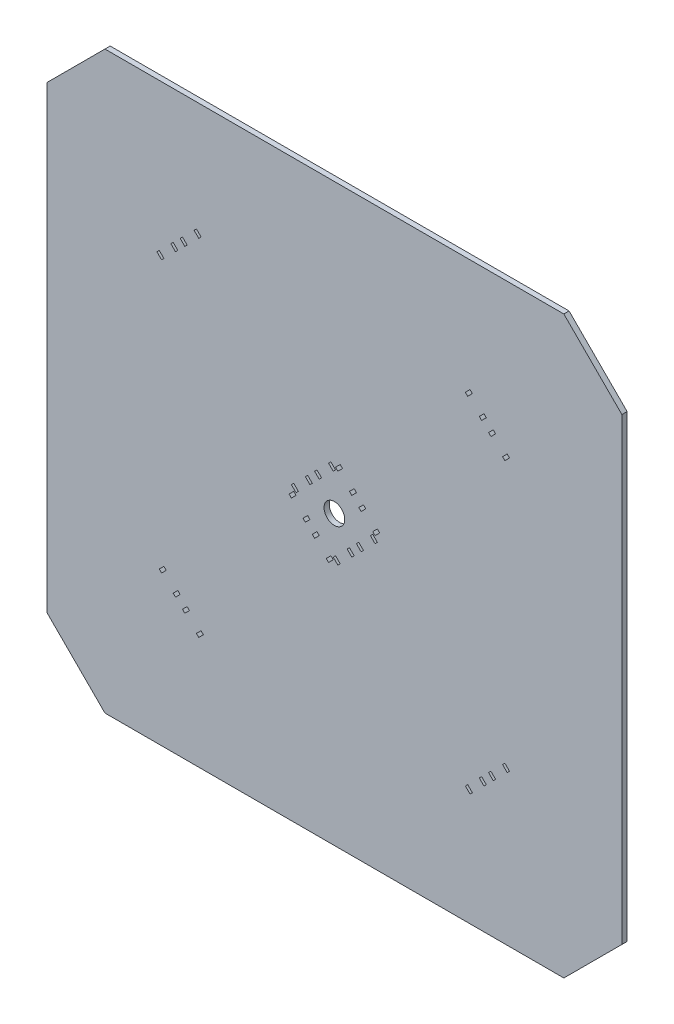
from build123d import *

# Parameters (mm, degrees)
MODEL_R             = 3.15
BOSS_EXTRUDE1_DEPTH = 1.59


with BuildPart() as part:
    # Model → Boss-Extrude1 (new body)
    with BuildSketch(Plane.XY):
        Polygon((0, 17.67766953), (0, 157.32233047), (17.67766953, 175), (157.32233047, 175), (175, 157.32233047), (175, 17.67766953), (157.32233047, 0), (17.67766953, 0), align=None)
        with Locations((87.5, 87.5)):
            Circle(MODEL_R, mode=Mode.SUBTRACT)
        Polygon((139.381727984, 47.639087297), (140.795941546, 46.224873734), (140.088834765, 45.517766953), (138.674621202, 46.931980515), align=None, mode=Mode.SUBTRACT)
        Polygon((135.139087297, 43.396446609), (136.553300859, 41.982233047), (135.846194078, 41.275126266), (134.431980515, 42.689339828), align=None, mode=Mode.SUBTRACT)
        Polygon((132.310660172, 40.568019485), (133.724873734, 39.153805922), (133.017766953, 38.446699141), (131.603553391, 39.860912703), align=None, mode=Mode.SUBTRACT)
        Polygon((128.068019485, 36.325378798), (129.482233047, 34.911165235), (128.775126266, 34.204058454), (127.360912703, 35.618272016), align=None, mode=Mode.SUBTRACT)
        Polygon((87.853553391, 76.539844892), (89.267766953, 75.125631329), (88.560660172, 74.418524548), (87.146446609, 75.83273811), align=None, mode=Mode.SUBTRACT)
        Polygon((92.096194078, 80.782485579), (93.51040764, 79.368272016), (92.803300859, 78.661165235), (91.389087297, 80.075378798), align=None, mode=Mode.SUBTRACT)
        Polygon((47.639087297, 35.618272016), (46.224873734, 34.204058454), (45.517766953, 34.911165235), (46.931980515, 36.325378798), align=None, mode=Mode.SUBTRACT)
        Polygon((43.396446609, 39.860912703), (41.982233047, 38.446699141), (41.275126266, 39.153805922), (42.689339828, 40.568019485), align=None, mode=Mode.SUBTRACT)
        Polygon((40.568019485, 42.689339828), (39.153805922, 41.275126266), (38.446699141, 41.982233047), (39.860912703, 43.396446609), align=None, mode=Mode.SUBTRACT)
        Polygon((36.325378798, 46.931980515), (34.911165235, 45.517766953), (34.204058454, 46.224873734), (35.618272016, 47.639087297), align=None, mode=Mode.SUBTRACT)
        Polygon((75.83273811, 86.439339828), (74.418524548, 85.025126266), (73.711417767, 85.732233047), (75.125631329, 87.146446609), align=None, mode=Mode.SUBTRACT)
        Polygon((80.075378798, 82.196699141), (78.661165235, 80.782485579), (77.954058454, 81.48959236), (79.368272016, 82.903805922), align=None, mode=Mode.SUBTRACT)
        Polygon((82.903805922, 79.368272016), (81.48959236, 77.954058454), (80.782485579, 78.661165235), (82.196699141, 80.075378798), align=None, mode=Mode.SUBTRACT)
        Polygon((87.146446609, 75.125631329), (85.732233047, 73.711417767), (85.025126266, 74.418524548), (86.439339828, 75.83273811), align=None, mode=Mode.SUBTRACT)
        Polygon((101.288582233, 89.267766953), (99.874368671, 87.853553391), (99.16726189, 88.560660172), (100.581475452, 89.974873734), align=None, mode=Mode.SUBTRACT)
        Polygon((97.045941546, 93.51040764), (95.631727984, 92.096194078), (94.924621202, 92.803300859), (96.338834765, 94.217514421), align=None, mode=Mode.SUBTRACT)
        Polygon((94.217514421, 96.338834765), (92.803300859, 94.924621202), (92.096194078, 95.631727984), (93.51040764, 97.045941546), align=None, mode=Mode.SUBTRACT)
        Polygon((89.974873734, 100.581475452), (88.560660172, 99.16726189), (87.853553391, 99.874368671), (89.267766953, 101.288582233), align=None, mode=Mode.SUBTRACT)
        Polygon((129.482233047, 140.088834765), (128.068019485, 138.674621202), (127.360912703, 139.381727984), (128.775126266, 140.795941546), align=None, mode=Mode.SUBTRACT)
        Polygon((133.724873734, 135.846194078), (132.310660172, 134.431980515), (131.603553391, 135.139087297), (133.017766953, 136.553300859), align=None, mode=Mode.SUBTRACT)
        Polygon((136.553300859, 133.017766953), (135.139087297, 131.603553391), (134.431980515, 132.310660172), (135.846194078, 133.724873734), align=None, mode=Mode.SUBTRACT)
        Polygon((140.795941546, 128.775126266), (139.381727984, 127.360912703), (138.674621202, 128.068019485), (140.088834765, 129.482233047), align=None, mode=Mode.SUBTRACT)
        Polygon((94.924621202, 83.610912703), (96.338834765, 82.196699141), (95.631727984, 81.48959236), (94.217514421, 82.903805922), align=None, mode=Mode.SUBTRACT)
        Polygon((99.16726189, 87.853553391), (100.581475452, 86.439339828), (99.874368671, 85.732233047), (98.460155108, 87.146446609), align=None, mode=Mode.SUBTRACT)
        Polygon((75.125631329, 89.267766953), (76.539844892, 87.853553391), (75.83273811, 87.146446609), (74.418524548, 88.560660172), align=None, mode=Mode.SUBTRACT)
        Polygon((79.368272016, 93.51040764), (80.782485579, 92.096194078), (80.075378798, 91.389087297), (78.661165235, 92.803300859), align=None, mode=Mode.SUBTRACT)
        Polygon((82.196699141, 96.338834765), (83.610912703, 94.924621202), (82.903805922, 94.217514421), (81.48959236, 95.631727984), align=None, mode=Mode.SUBTRACT)
        Polygon((86.439339828, 100.581475452), (87.853553391, 99.16726189), (87.146446609, 98.460155108), (85.732233047, 99.874368671), align=None, mode=Mode.SUBTRACT)
        Polygon((34.204058454, 130.189339828), (35.618272016, 128.775126266), (34.911165235, 128.068019485), (33.496951673, 129.482233047), align=None, mode=Mode.SUBTRACT)
        Polygon((38.446699141, 134.431980515), (39.860912703, 133.017766953), (39.153805922, 132.310660172), (37.73959236, 133.724873734), align=None, mode=Mode.SUBTRACT)
        Polygon((41.275126266, 137.26040764), (42.689339828, 135.846194078), (41.982233047, 135.139087297), (40.568019485, 136.553300859), align=None, mode=Mode.SUBTRACT)
        Polygon((45.517766953, 141.503048327), (46.931980515, 140.088834765), (46.224873734, 139.381727984), (44.810660172, 140.795941546), align=None, mode=Mode.SUBTRACT)
    extrude(amount=BOSS_EXTRUDE1_DEPTH)


solid = part.part
